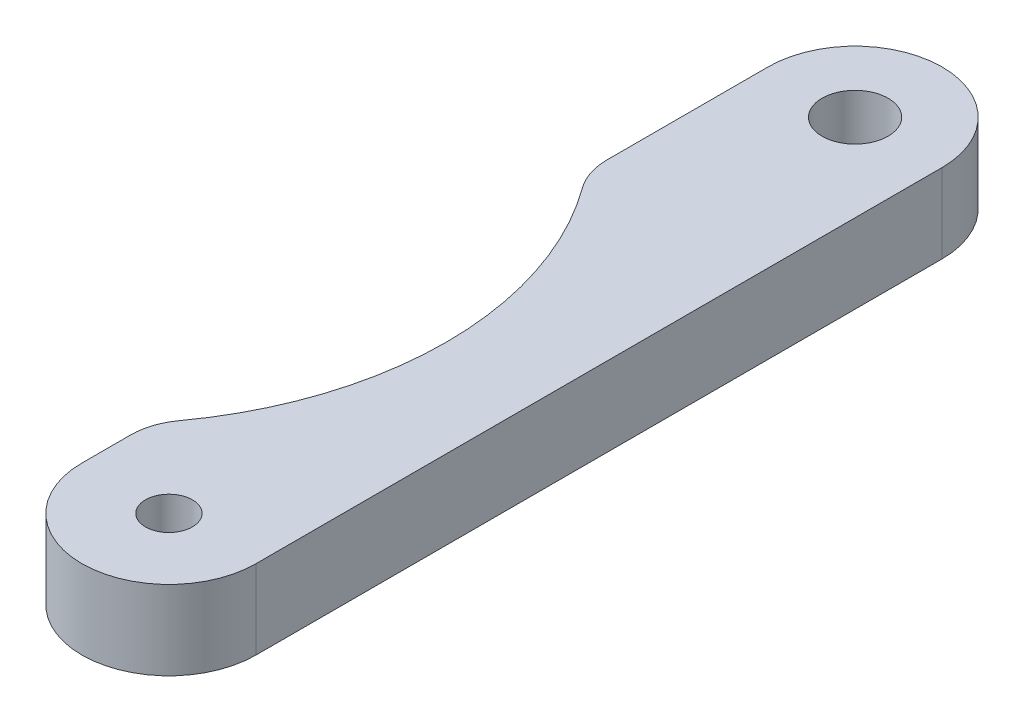
from build123d import *

# Parameters (mm, degrees)
BOSS_EXTRUDE1_DEPTH   = 3.81
F_4_40_TAPPED_HOLE1_D = 2.2606
CUT_EXTRUDE1_DEPTH    = 4.81
SKETCH5_R             = 1.5875
CUT_EXTRUDE2_DEPTH    = 4.81
FILLET1_R             = 3


with BuildPart() as part:
    # Sketch1 → Boss-Extrude1 (new body)
    with BuildSketch(Plane(origin=(0, 0, 0), x_dir=(1, 0, 0), z_dir=(0, 1, 0))):
        with BuildLine():
            Line((0.307655172, 6.517241379), (0.307655172, -26.502758621))
            ThreePointArc((0.307655172, -26.502758621), (4.498655172, -30.693758621), (8.689655172, -26.502758621))
            Line((8.689655172, -26.502758621), (8.689655172, 6.517241379))
            ThreePointArc((8.689655172, 6.517241379), (4.498655172, 10.708241379), (0.307655172, 6.517241379))
        make_face()
    extrude(amount=BOSS_EXTRUDE1_DEPTH)

    # #4-40 Tapped Hole1 (through all)
    with Locations(Plane(origin=(0, 3.81, 0), x_dir=(1, 0, 0), z_dir=(0, 1, 0))):
        with Locations((4.498655172, 6.517241379), (4.498655172, -26.502758621)):
            Hole(F_4_40_TAPPED_HOLE1_D / 2)

    # Sketch4 → Cut-Extrude1 (cut, through all)
    with BuildSketch(Plane(origin=(0, 3.81, 0), x_dir=(1, 0, 0), z_dir=(0, 1, 0))):
        with BuildLine():
            Line((-105.054689706, 41.50252919), (-22.868233876, -25.472974727))
            ThreePointArc((-22.868233876, -25.472974727), (0.331829627, -23.107123199), (-2.0340219, 0.092940304))
            Line((-2.0340219, 0.092940304), (-84.220477731, 67.068444221))
            Line((-84.220477731, 67.068444221), (-248.593389391, 201.019452054))
            Line((-248.593389391, 201.019452054), (-269.427601367, 175.453537024))
            Line((-269.427601367, 175.453537024), (-105.054689706, 41.50252919))
        make_face()
    extrude(amount=-CUT_EXTRUDE1_DEPTH, mode=Mode.SUBTRACT)

    # Sketch5 → Cut-Extrude2 (cut, through all)
    with BuildSketch(Plane(origin=(0, 3.81, 0), x_dir=(1, 0, 0), z_dir=(0, 1, 0))):
        with Locations((4.498655172, 6.517241379)):
            Circle(SKETCH5_R)
    extrude(amount=-CUT_EXTRUDE2_DEPTH, mode=Mode.SUBTRACT)

    # Fillet1
    fillet1_edges = [part.edges().sort_by_distance(p)[0] for p in [
        (0.307655172, 1.905, 23.136717878),
        (0.307655172, 1.905, 2.243316545),
    ]]
    fillet(fillet1_edges, radius=FILLET1_R)


solid = part.part
